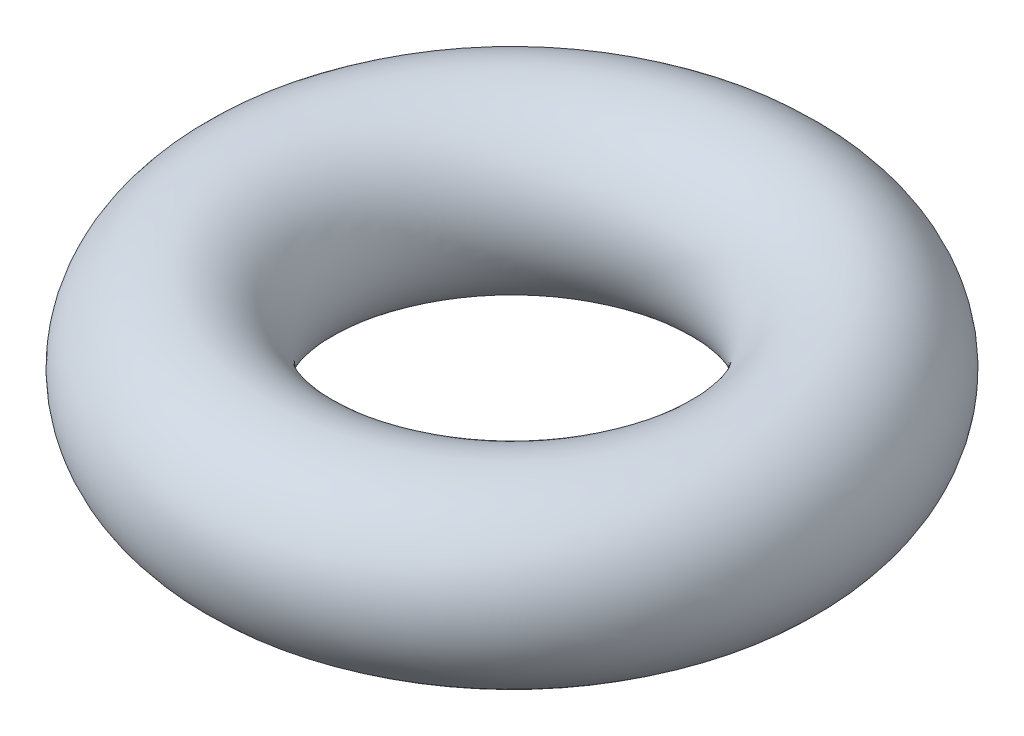
from build123d import *

# Parameters (mm, degrees)
SKETCH1_R = 1


with BuildPart() as part:
    # Sketch1 → Revolve1 (revolve)
    with BuildSketch(Plane(origin=(0, 0, 0), x_dir=(0, 0, -1), z_dir=(1, 0, 0))):
        with Locations((2.75, 0)):
            Circle(SKETCH1_R)
    revolve(axis=Axis((0, 0.610594796, 0), (0, -1, 0)))


solid = part.part
